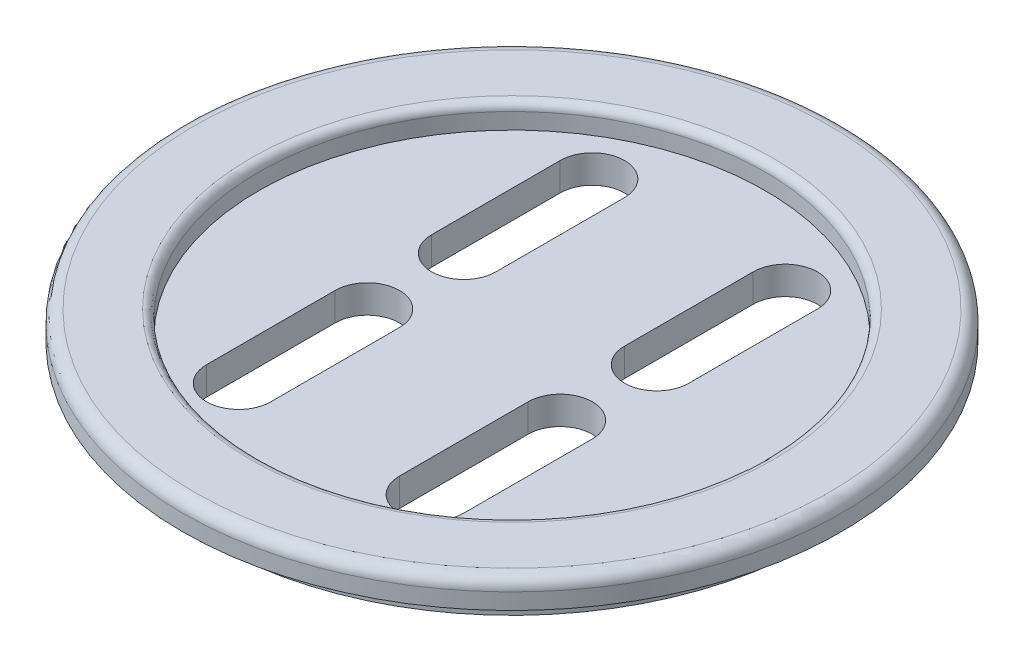
from build123d import *

# Parameters (mm, degrees)
SKETCH1_R               = 375
BOSS_EXTRUDE1_DEPTH     = 30
SKETCH1_7_R             = 410
BOSS_EXTRUDE2_DEPTH     = 35
CUT_EXTRUDE1_DEPTH      = 36
CUT_EXTRUDE1_DEPTH_BACK = 31
CUT_EXTRUDE2_START      = 35
SKETCH1_14_R            = 315
CUT_EXTRUDE2_DEPTH      = 30
FILLET1_R               = 15
FILLET2_R               = 10


with BuildPart() as part:
    # Sketch1 → Boss-Extrude1 (new body)
    with BuildSketch(Plane(origin=(0, 0, 0), x_dir=(1, 0, 0), z_dir=(0, 1, 0))):
        Circle(SKETCH1_R)
    extrude(amount=-BOSS_EXTRUDE1_DEPTH)

    # Sketch1_7 → Boss-Extrude2 (add)
    with BuildSketch(Plane(origin=(0, 0, 0), x_dir=(1, 0, 0), z_dir=(0, 1, 0))):
        Circle(SKETCH1_7_R)
    extrude(amount=BOSS_EXTRUDE2_DEPTH)

    # Sketch1_10 → Cut-Extrude1 (cut, two sides)
    with BuildSketch(Plane(origin=(0, 0, 0), x_dir=(1, 0, 0), z_dir=(0, 1, 0))) as cut_extrude1_sk:
        with BuildLine():
            Line((-80, 220), (-80, 60))
            ThreePointArc((-80, 60), (-120, 20), (-160, 60))
            Line((-160, 60), (-160, 220))
            ThreePointArc((-160, 220), (-120, 260), (-80, 220))
        make_face()
        with BuildLine():
            Line((-80, -220), (-80, -60))
            ThreePointArc((-80, -60), (-120, -20), (-160, -60))
            Line((-160, -60), (-160, -220))
            ThreePointArc((-160, -220), (-120, -260), (-80, -220))
        make_face()
        with BuildLine():
            Line((80, 220), (80, 60))
            ThreePointArc((80, 60), (120, 20), (160, 60))
            Line((160, 60), (160, 220))
            ThreePointArc((160, 220), (120, 260), (80, 220))
        make_face()
        with BuildLine():
            Line((80, -220), (80, -60))
            ThreePointArc((80, -60), (120, -20), (160, -60))
            Line((160, -60), (160, -220))
            ThreePointArc((160, -220), (120, -260), (80, -220))
        make_face()
    extrude(amount=CUT_EXTRUDE1_DEPTH, mode=Mode.SUBTRACT)
    extrude(cut_extrude1_sk.sketch, amount=-CUT_EXTRUDE1_DEPTH_BACK, mode=Mode.SUBTRACT)

    # Sketch1_14 → Cut-Extrude2 (cut)
    with BuildSketch(Plane(origin=(0, 0, 0), x_dir=(1, 0, 0), z_dir=(0, 1, 0)).offset(CUT_EXTRUDE2_START)):
        Circle(SKETCH1_14_R)
    extrude(amount=-CUT_EXTRUDE2_DEPTH, mode=Mode.SUBTRACT)

    # Fillet1
    fillet1_edges = [part.edges().sort_by_distance(p)[0] for p in [
        (-410, 35, 0),
    ]]
    fillet(fillet1_edges, radius=FILLET1_R)

    # Fillet2
    fillet2_edges = [part.edges().sort_by_distance(p)[0] for p in [
        (-315, 35, 0),
    ]]
    fillet(fillet2_edges, radius=FILLET2_R)


solid = part.part
